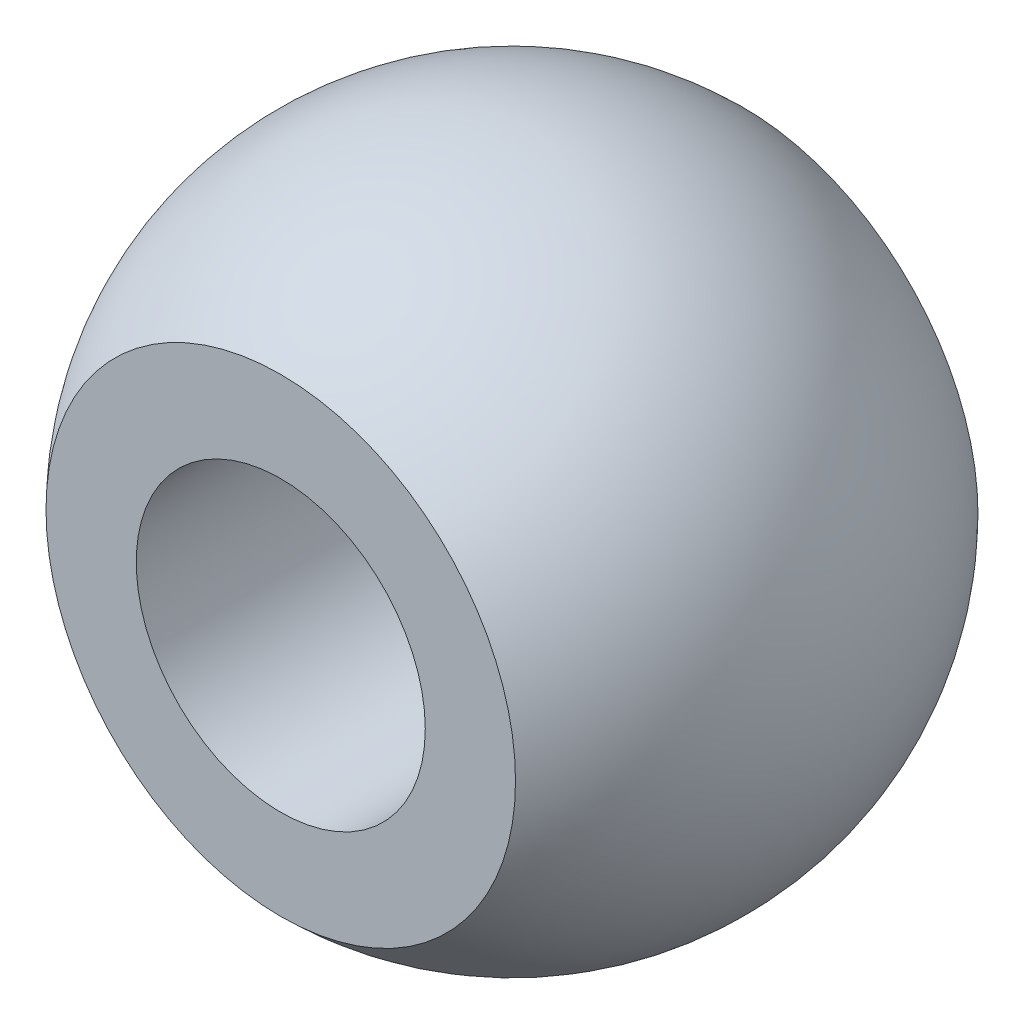
from build123d import *

# Parameters (mm, degrees)
CUT_EXTRUDE1_DEPTH      = 10.872689603
CUT_EXTRUDE1_DEPTH_BACK = 10.872689603
SKETCH2_W               = 13.726574523
SKETCH2_H               = 3.768207789
SKETCH3_R               = 2.5
CUT_EXTRUDE2_DEPTH      = 10


with BuildPart() as part:
    # Sketch1 → Revolve3 (revolve)
    with BuildSketch(Plane.XY):
        with BuildLine():
            Line((0, 5.7), (0, -2.5))
            Line((0, -2.5), (0, -5.7))
            ThreePointArc((0, -5.7), (-5.7, 0), (0, 5.7))
        make_face()
    revolve(axis=Axis((0, 5.7, 0), (0, -1, 0)))

    # Sketch2 → Cut-Extrude1 (cut, two sides: drawn at the far end of the back side and taken through both)
    with BuildSketch(Plane(origin=(0, 0, 0), x_dir=(1, 0, 0), z_dir=(0, 1, 0)).offset(-CUT_EXTRUDE1_DEPTH_BACK)):
        with Locations((0.542276875, 5.884103895)):
            Rectangle(SKETCH2_W, SKETCH2_H)
        with Locations((0.542276875, -5.884103895)):
            Rectangle(SKETCH2_W, SKETCH2_H)
    extrude(amount=CUT_EXTRUDE1_DEPTH + CUT_EXTRUDE1_DEPTH_BACK, mode=Mode.SUBTRACT)

    # Sketch3 → Cut-Extrude2 (cut)
    with BuildSketch(Plane.XY.offset(4)):
        Circle(SKETCH3_R)
    extrude(amount=-CUT_EXTRUDE2_DEPTH, mode=Mode.SUBTRACT)


solid = part.part
